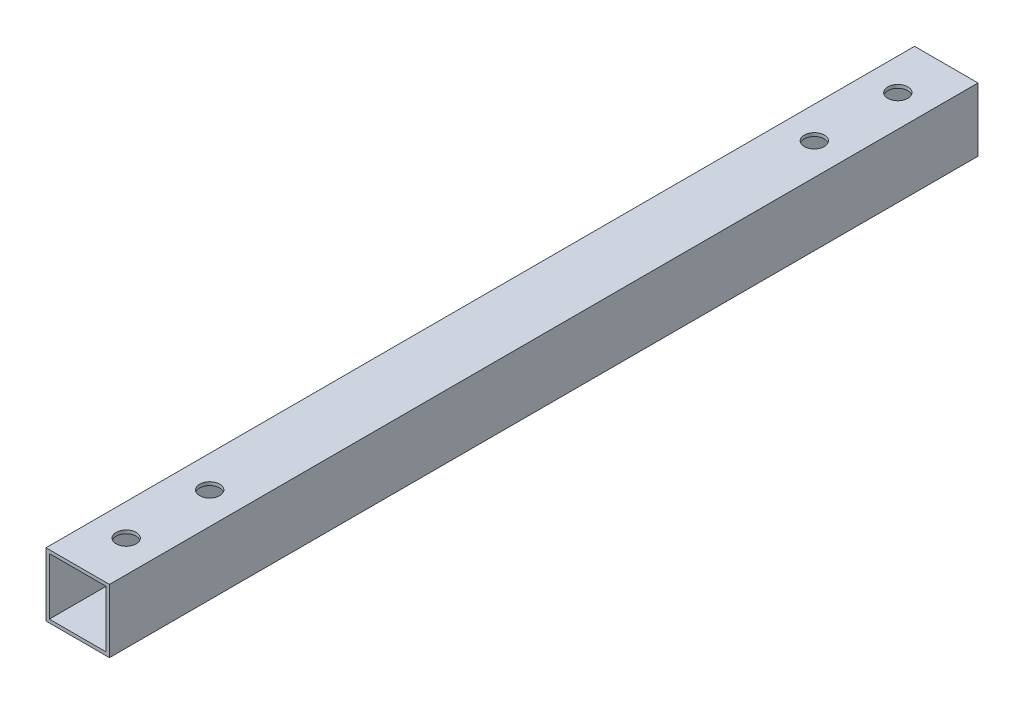
from build123d import *

# Parameters (mm, degrees)
ESBO_O1_W                = 19
ESBO_O1_H                = 19
RESSALTO_EXTRUS_O1_DEPTH = 260
CASCA2_T                 = -1
ESBO_O2_R                = 3
CORTE_EXTRUS_O1_DEPTH    = 20


with BuildPart() as part:
    # Esboço1 → Ressalto-extrusão1 (new body)
    with BuildSketch(Plane.XY):
        Rectangle(ESBO_O1_W, ESBO_O1_H)
    extrude(amount=RESSALTO_EXTRUS_O1_DEPTH)

    # Casca2
    casca2_openings = [part.faces().sort_by_distance(p)[0] for p in [
        (0, 0, 260),
        (0, 0, 0),
    ]]
    offset(amount=CASCA2_T, openings=casca2_openings, kind=Kind.INTERSECTION)

    # Esboço2 → Corte-extrusão1 (cut, through all)
    with BuildSketch(Plane(origin=(0, 9.5, 0), x_dir=(1, 0, 0), z_dir=(0, 1, 0))):
        with Locations((0, -220.5)):
            Circle(ESBO_O2_R)
        with Locations((0, -245.5)):
            Circle(ESBO_O2_R)
        with Locations((0, -14.5)):
            Circle(ESBO_O2_R)
        with Locations((0, -39.5)):
            Circle(ESBO_O2_R)
    extrude(amount=-CORTE_EXTRUS_O1_DEPTH, mode=Mode.SUBTRACT)


solid = part.part
